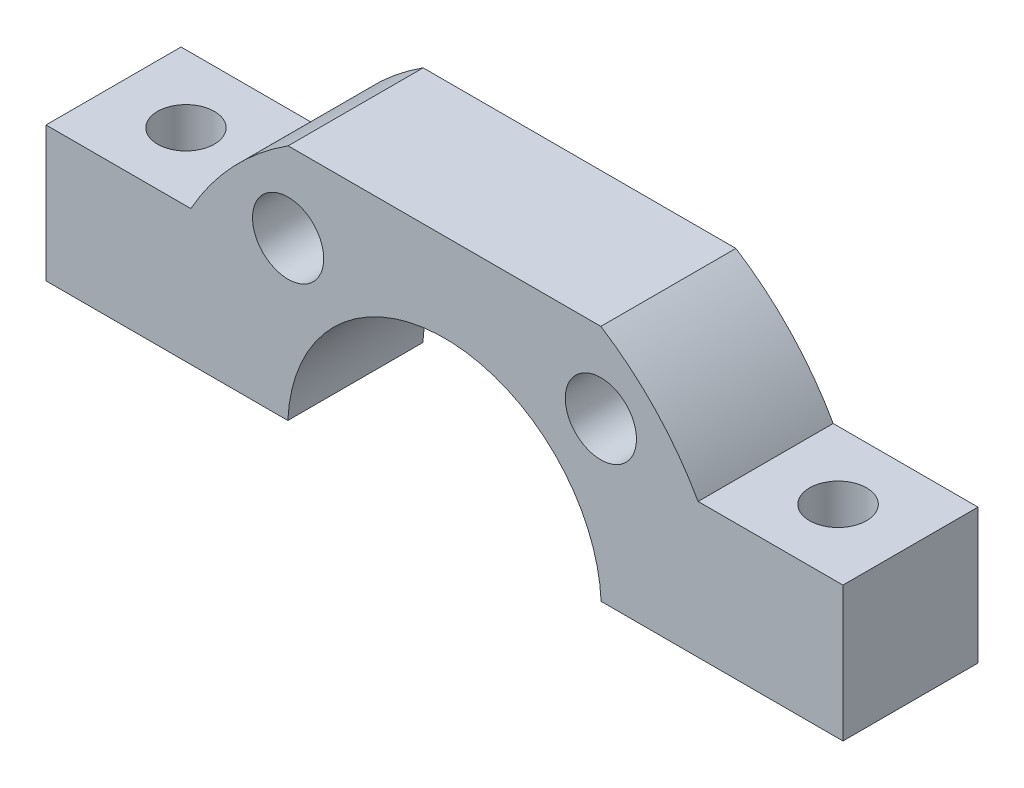
from build123d import *

# Parameters (mm, degrees)
SKETCH1_R           = 2.505
BOSS_EXTRUDE2_DEPTH = 9.5
CUT_EXTRUDE1_REACH  = 12
SKETCH2_R           = 2.005
SKETCH2_R_2         = 2
SKETCH3_W           = 72.995776
SKETCH3_H           = 18.148858384
CUT_EXTRUDE2_DEPTH  = 0.5


with BuildPart() as part:
    # Sketch1 → Boss-Extrude2 (new body)
    with BuildSketch(Plane.XY):
        with BuildLine():
            Line((-11.03, 0), (-28.03, 0))
            Line((-28.03, 0), (-28.03, 10))
            Line((-28.03, 10), (-17.842887818, 10))
            ThreePointArc((-17.842887818, 10), (-14.869374743, 14.045296026), (-11, 17.244380119))
            Line((-11, 17.244380119), (11, 17.244380119))
            ThreePointArc((11, 17.244380119), (14.869374743, 14.045296026), (17.842887818, 10))
            Line((17.842887818, 10), (28.03, 10))
            Line((28.03, 10), (28.03, 0))
            Line((28.03, 0), (11.03, 0))
            ThreePointArc((11.03, 0), (0, 11.03), (-11.03, 0))
        make_face()
        with Locations((11, 11.618950039)):
            Circle(SKETCH1_R, mode=Mode.SUBTRACT)
        with Locations((-11, 11.618950039)):
            Circle(SKETCH1_R, mode=Mode.SUBTRACT)
    extrude(amount=BOSS_EXTRUDE2_DEPTH)

    # Sketch2 → Cut-Extrude1 (cut, up to next)
    with BuildSketch(Plane(origin=(0, 10, 0), x_dir=(1, 0, 0), z_dir=(0, 1, 0)), mode=Mode.PRIVATE) as cut_extrude1_sk1:
        with Locations((22.936443909, -4.75)):
            Circle(SKETCH2_R)
    cut_extrude1_tool1 = extrude(cut_extrude1_sk1.sketch, amount=-CUT_EXTRUDE1_REACH, mode=Mode.PRIVATE) & part.part
    add(cut_extrude1_tool1.solids().sort_by_distance((22.936444, 10, 4.75))[0], mode=Mode.SUBTRACT)
    # Sketch2 → Cut-Extrude1 (cut, up to next)
    with BuildSketch(Plane(origin=(0, 10, 0), x_dir=(1, 0, 0), z_dir=(0, 1, 0)), mode=Mode.PRIVATE) as cut_extrude1_sk2:
        with Locations((-22.936443909, -4.75)):
            Circle(SKETCH2_R_2)
    cut_extrude1_tool2 = extrude(cut_extrude1_sk2.sketch, amount=-CUT_EXTRUDE1_REACH, mode=Mode.PRIVATE) & part.part
    add(cut_extrude1_tool2.solids().sort_by_distance((-22.936444, 10, 4.75))[0], mode=Mode.SUBTRACT)

    # Sketch3 → Cut-Extrude2 (cut)
    with BuildSketch(Plane.XZ):
        with Locations((1.301113009, 1.807163247)):
            Rectangle(SKETCH3_W, SKETCH3_H)
    extrude(amount=-CUT_EXTRUDE2_DEPTH, mode=Mode.SUBTRACT)


solid = part.part
